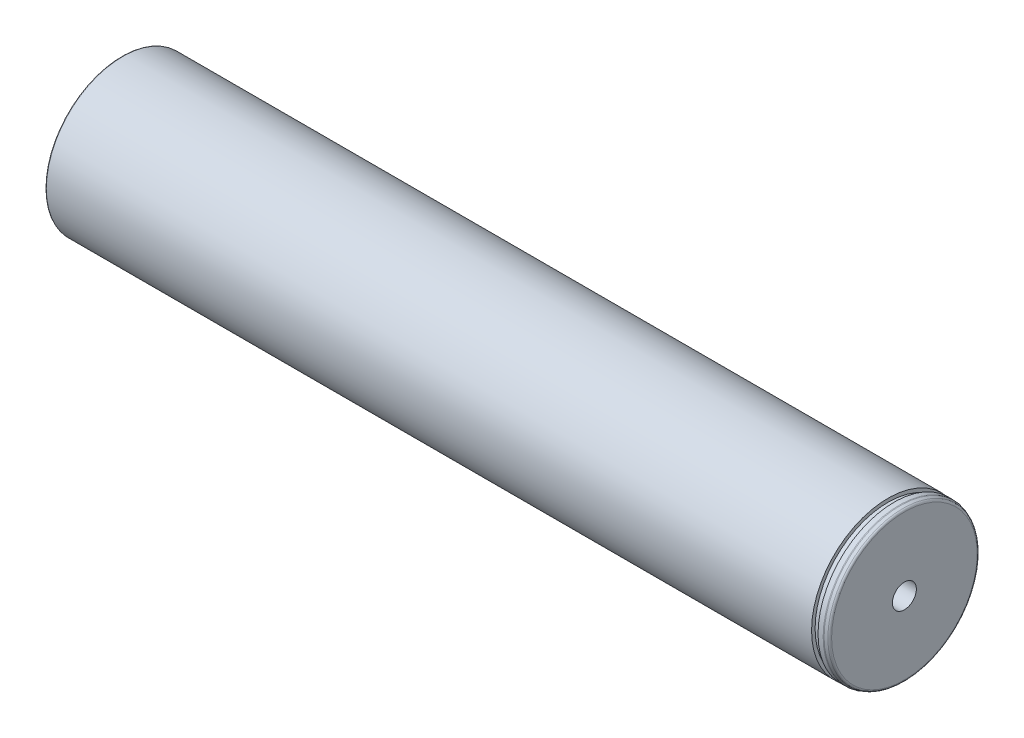
from build123d import *


with BuildPart() as part:
    # Sketch1 → Base-Revolve (revolve)
    with BuildSketch(Plane.XY):
        with BuildLine():
            Line((163, 32.5), (0, 32.5))
            Line((0, 32.5), (-162.6, 32.5))
            ThreePointArc((-162.6, 32.5), (-162.882842712, 32.382842712), (-163, 32.1))
            Line((-163, 32.1), (-163, 28.4))
            ThreePointArc((-163, 28.4), (-163.117157288, 28.117157288), (-163.4, 28))
            Line((-163.4, 28), (-164, 28))
            Line((-164, 28), (-164, 25.230940108))
            ThreePointArc((-164, 25.230940108), (-164.053589838, 25.030940108), (-164.2, 24.884529946))
            Line((-164.2, 24.884529946), (-167.8, 22.806068977))
            ThreePointArc((-167.8, 22.806068977), (-167.946410162, 22.659658816), (-168, 22.459658816))
            Line((-168, 22.459658816), (-168, 5.1))
            Line((-168, 5.1), (-148, 5.1))
            Line((-148, 5.1), (-145.055513627, 0))
            Line((-145.055513627, 0), (147.055513627, 0))
            Line((147.055513627, 0), (150, 5.1))
            Line((150, 5.1), (170, 5.1))
            Line((170, 5.1), (170, 30.971851993))
            ThreePointArc((170, 30.971851993), (169.819152044, 31.54542843), (169.342020143, 31.911544614))
            Line((169.342020143, 31.911544614), (168.165693163, 32.339692621))
            ThreePointArc((168.165693163, 32.339692621), (167.997321197, 32.384807753), (167.823673019, 32.4))
            Line((167.823673019, 32.4), (165.65, 32.4))
            Line((165.65, 32.4), (165.65, 31))
            Line((165.65, 31), (163, 31))
            Line((163, 31), (163, 32.5))
        make_face()
    revolve(axis=Axis((-168, 0, 0), (1, 0, 0)))


solid = part.part
